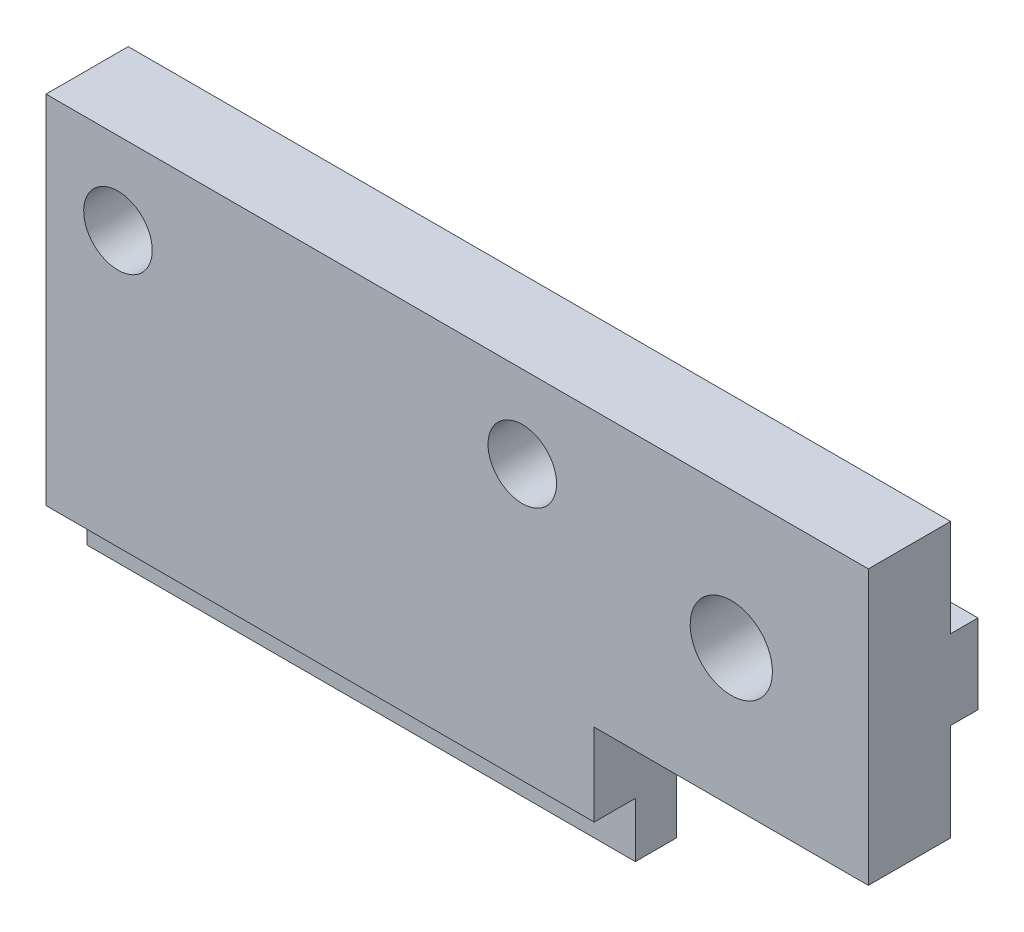
from build123d import *

# Parameters (mm, degrees)
SKETCH1_R              = 1.25
SKETCH1_R_2            = 1.5
MAIN_DEPTH             = 3
SKETCH2_W              = 20
SKETCH2_H              = 2
PINHOLES_DEPTH         = 1.5
SKETCH3_W              = 1
SKETCH3_H              = 2.9
MAKERBEAMSUPPORT_DEPTH = 30
SKETCH4_R              = 1.25
SKETCH4_R_2            = 1.5
HOLES2_DEPTH           = 5


with BuildPart() as part:
    # Sketch1 → Main (new body)
    with BuildSketch(Plane.XY):
        Polygon((-10, -7.5), (10, -7.5), (10, -2.5), (20, -2.5), (20, 7.5), (-10, 7.5), align=None)
        with Locations((-7.375, 4.5)):
            Circle(SKETCH1_R, mode=Mode.SUBTRACT)
        with Locations((7.375, 4.5)):
            Circle(SKETCH1_R, mode=Mode.SUBTRACT)
        with Locations((15, 2.5)):
            Circle(SKETCH1_R_2, mode=Mode.SUBTRACT)
    extrude(amount=MAIN_DEPTH)

    # Sketch2 → PinHoles (cut)
    with BuildSketch(Plane.XY.offset(3)):
        with Locations((0, -6.5)):
            Rectangle(SKETCH2_W, SKETCH2_H)
    extrude(amount=-PINHOLES_DEPTH, mode=Mode.SUBTRACT)

    # Sketch3 → MakerBeamSupport (add)
    with BuildSketch(Plane.ZY.offset(10)):
        with Locations((-0.5, 2.5)):
            Rectangle(SKETCH3_W, SKETCH3_H)
    extrude(amount=-MAKERBEAMSUPPORT_DEPTH)

    # Sketch4 → Holes2 (cut, through all)
    with BuildSketch(Plane.XY.offset(3)):
        with Locations((-7.375, 4.5)):
            Circle(SKETCH4_R)
        with Locations((7.375, 4.5)):
            Circle(SKETCH4_R)
        with Locations((15, 2.5)):
            Circle(SKETCH4_R_2)
    extrude(amount=-HOLES2_DEPTH, mode=Mode.SUBTRACT)


solid = part.part
